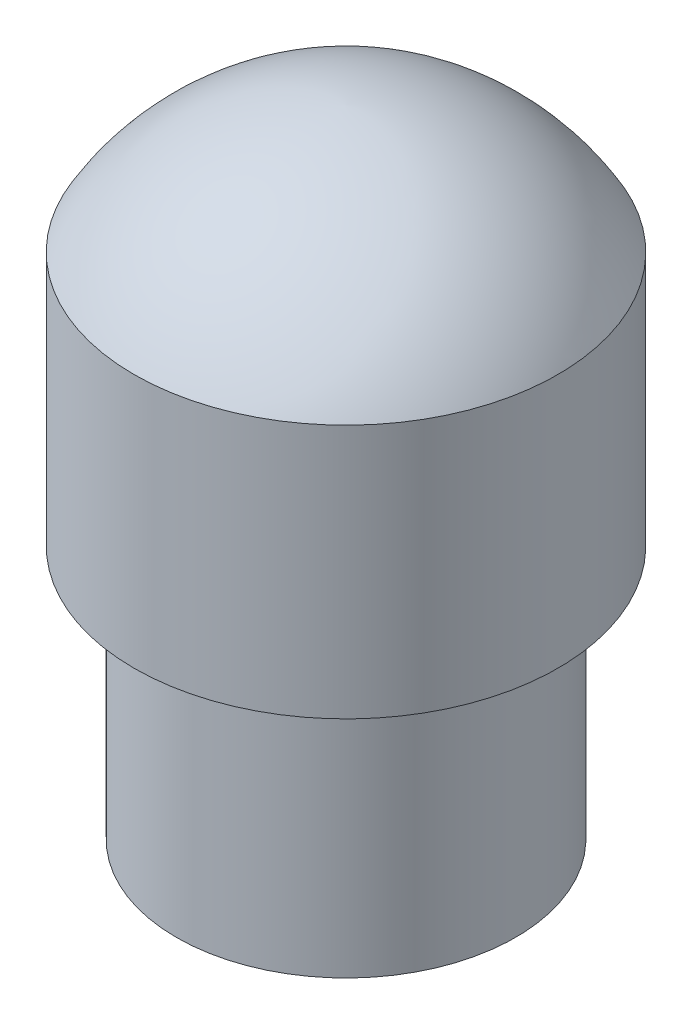
from build123d import *

# Parameters (mm, degrees)
CUT_EXTRUDE1_DEPTH = 7


with BuildPart() as part:
    # Sketch1 → Revolve1 (revolve)
    with BuildSketch(Plane.XY):
        with BuildLine():
            Line((0, 0), (0, 15))
            ThreePointArc((0, 15), (2.888936029, 14.148226716), (5, 12))
            Line((5, 12), (5, 6))
            Line((5, 6), (4, 6))
            Line((4, 6), (4, 0))
            Line((4, 0), (0, 0))
        make_face()
    revolve(axis=Axis((0, 0, 0), (0, 1, 0)))

    # Sketch2 → Cut-Extrude1 (cut)
    with BuildSketch(Plane.XZ):
        Polygon((1.443375673, -2.5), (2.886751346, 0), (1.443375673, 2.5), (-1.443375673, 2.5), (-2.886751346, 0), (-1.443375673, -2.5), align=None)
    extrude(amount=-CUT_EXTRUDE1_DEPTH, mode=Mode.SUBTRACT)


solid = part.part
